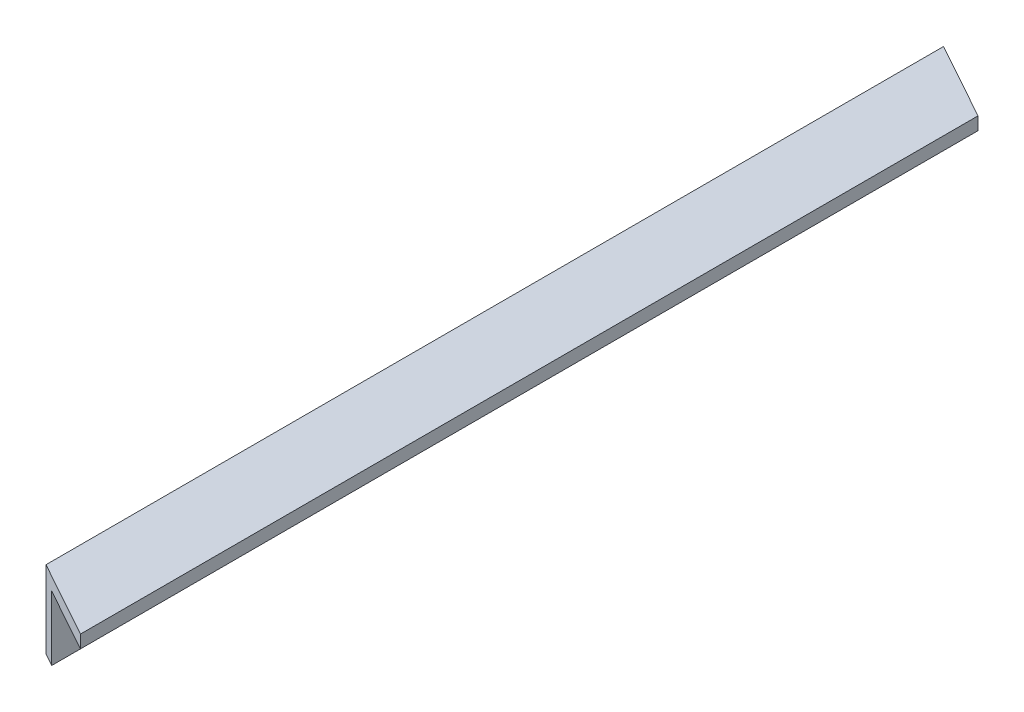
from build123d import *

# Parameters (mm, degrees)
OAL_ANGLE_DEPTH     = 463.55
ANGLE_CUTOURT_DEPTH = 39.1


with BuildPart() as part:
    # Sketch1 → OAL Angle (new body)
    with BuildSketch(Plane.XY):
        Polygon((0, 0), (0, -38.1), (6.35, -38.1), (6.35, -6.35), (38.1, -6.35), (38.1, 0), align=None)
    extrude(amount=OAL_ANGLE_DEPTH)

    # Sketch2 → Angle Cutourt (cut, through all)
    with BuildSketch(Plane(origin=(0, 0, 0), x_dir=(1, 0, 0), z_dir=(0, 1, 0))):
        Polygon((0, 0), (38.1, -21.11917486), (38.1, 0), align=None)
        Polygon((38.1, -463.55), (0, -442.43082514), (0, -463.55), align=None)
    extrude(amount=-ANGLE_CUTOURT_DEPTH, mode=Mode.SUBTRACT)


solid = part.part
